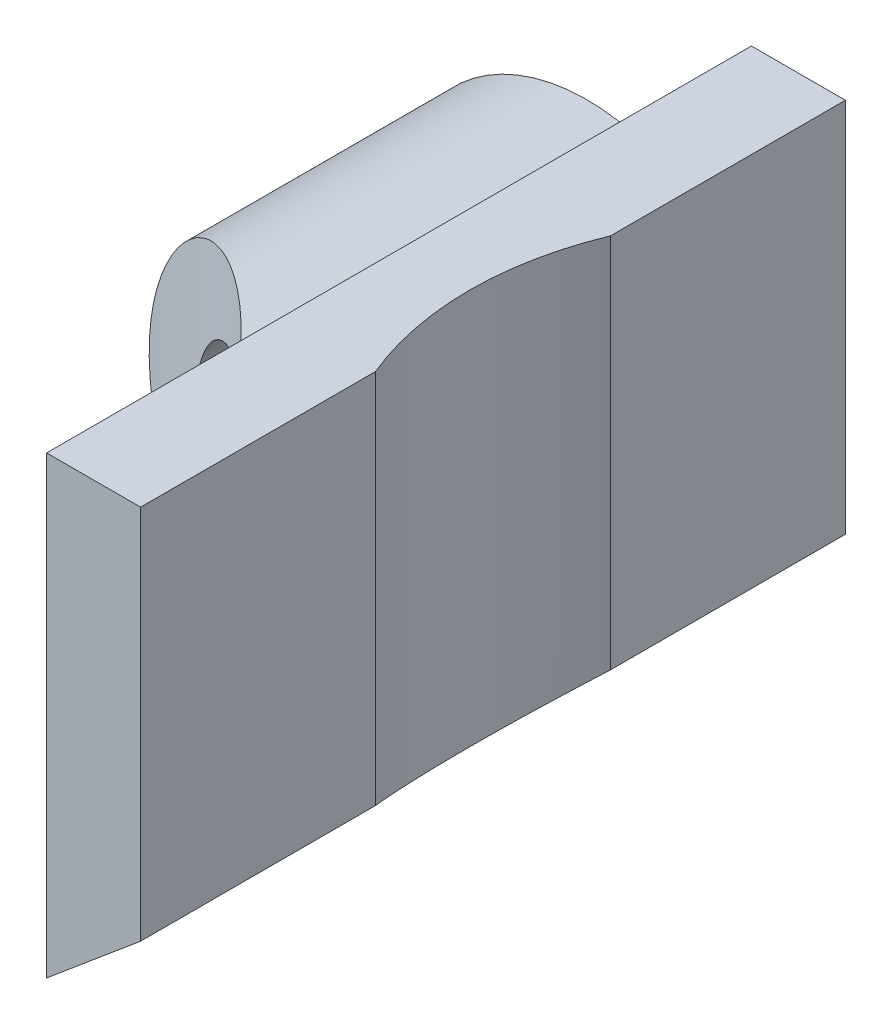
from build123d import *

# Parameters (mm, degrees)
SKETCH_1_R          = 2.5
EXTRUDE_1_DEPTH     = 15
SKETCH_2_OUTSIDE_W  = 15.65
SKETCH_2_OUTSIDE_H  = 21.15
CUT_EXTRUDE_1_DEPTH = 11.740715169


with BuildPart() as part:
    # 草圖1 → 填料-伸長1 (new body)
    with BuildSketch(Plane.XY):
        with BuildLine():
            Line((3.5, -2.937484093), (5.5, -1.259284831))
            Line((5.5, -1.259284831), (5.5, 6.740715169))
            Line((5.5, 6.740715169), (3.5, 6.740715169))
            Line((3.5, 6.740715169), (3.5, 5.809475019))
            ThreePointArc((3.5, 5.809475019), (2.724744871, 4.228336189), (1, 3.872983346))
            ThreePointArc((1, 3.872983346), (-3.878905774, -0.976775304), (2.714993039, -2.937484093))
            Line((2.714993039, -2.937484093), (3.5, -2.937484093))
        make_face()
        Circle(SKETCH_1_R, mode=Mode.SUBTRACT)
    extrude(amount=EXTRUDE_1_DEPTH)

    # 草圖2 outside → 除料-伸長1 (cut, through all)
    with BuildSketch(Plane(origin=(0, 6.740715169, 0), x_dir=(1, 0, 0), z_dir=(0, 1, 0))):
        with Locations((0.75, -7.5)):
            Rectangle(SKETCH_2_OUTSIDE_W, SKETCH_2_OUTSIDE_H)
        with BuildLine():
            Line((5.5, -15), (3.5, -15))
            ThreePointArc((3.5, -15), (0.571067812, -7.928932188), (-6.5, -5))
            Line((-6.5, -5), (-4, -5))
            Line((-4, -5), (-4, 0))
            Line((-4, 0), (5.5, 0))
            Line((5.5, 0), (5.5, -5))
            ThreePointArc((5.5, -5), (5, -7.5), (5.5, -10))
            Line((5.5, -10), (5.5, -15))
        make_face(mode=Mode.SUBTRACT)
    extrude(amount=-CUT_EXTRUDE_1_DEPTH, mode=Mode.SUBTRACT)


solid = part.part
